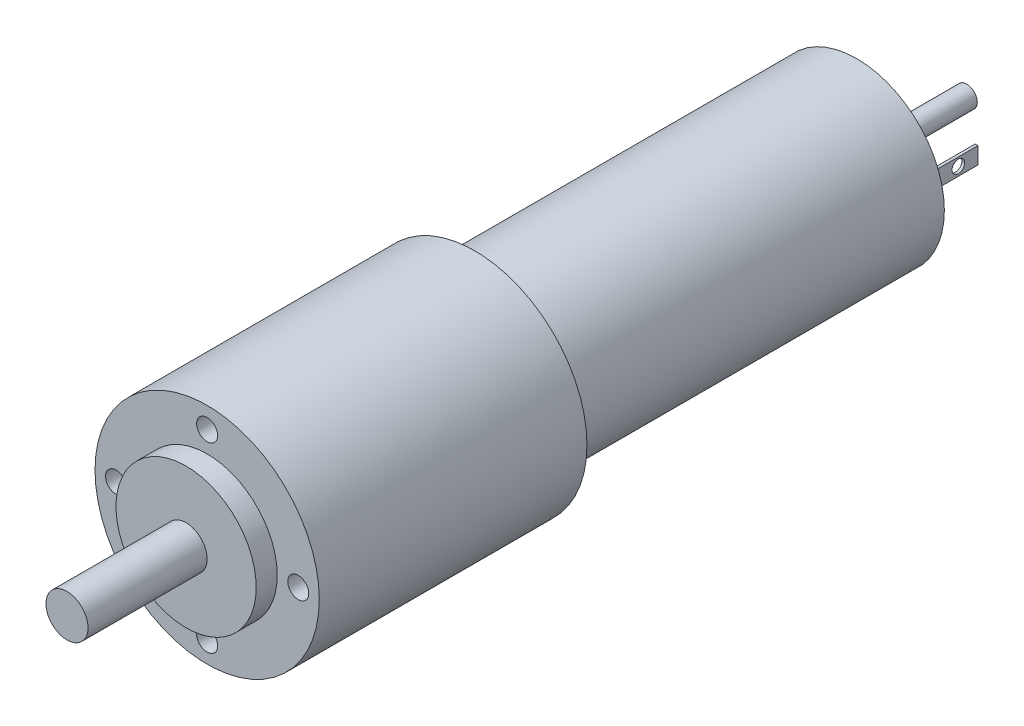
from build123d import *

# Parameters (mm, degrees)
ESQUISSE1_R                  = 16
BOSS_EXTRU_1_DEPTH           = 38.2
ESQUISSE4_R                  = 12.5
BOSS_EXTRU_2_DEPTH           = 54.5
ESQUISSE5_R                  = 10
BOSS_EXTRU_3_DEPTH           = 3
ESQUISSE6_R                  = 3
BOSS_EXTRU_4_DEPTH           = 17
ESQUISSE8_R                  = 4
BOSS_EXTRU_5_DEPTH           = 1.2
ESQUISSE9_R                  = 3
BOSS_EXTRU_6_DEPTH           = 1.5
ESQUISSE10_R                 = 1.5
BOSS_EXTRU_7_DEPTH           = 13
ESQUISSE11_W                 = 0.4
ESQUISSE11_H                 = 2.4
BOSS_EXTRU_8_DEPTH           = 8.3
ESQUISSE14_R                 = 0.9
ENL_V_MAT_EXTRU_2_DEPTH      = 1
R_P_TITION_CIRCULAIRE3_COUNT = 2
R_P_TITION_CIRCULAIRE4_COUNT = 2
ESQUISSE15_R                 = 0.8
ENL_V_MAT_EXTRU_3_DEPTH      = 3
R_P_TITION_CIRCULAIRE5_COUNT = 2
ESQUISSE16_R                 = 1.5
ENL_V_MAT_EXTRU_4_DEPTH      = 4
R_P_TITION_CIRCULAIRE6_COUNT = 4


with BuildPart() as part:
    # Esquisse1 → Boss.-Extru.1 (new body)
    with BuildSketch(Plane.XY):
        Circle(ESQUISSE1_R)
    extrude(amount=BOSS_EXTRU_1_DEPTH)

    # Esquisse4 → Boss.-Extru.2 (add)
    with BuildSketch(Plane(origin=(0, 0, 0), x_dir=(-1, 0, 0), z_dir=(0, 0, -1))):
        with Locations(Location((0, 0, 0), (0, 0, 180))):
            Circle(ESQUISSE4_R)
    extrude(amount=BOSS_EXTRU_2_DEPTH)

    # Esquisse5 → Boss.-Extru.3 (add)
    with BuildSketch(Plane.XY.offset(38.2)):
        Circle(ESQUISSE5_R)
    extrude(amount=BOSS_EXTRU_3_DEPTH)

    # Esquisse6 → Boss.-Extru.4 (add)
    with BuildSketch(Plane.XY.offset(41.2)):
        Circle(ESQUISSE6_R)
    extrude(amount=BOSS_EXTRU_4_DEPTH)

    # Esquisse8 → Boss.-Extru.5 (add)
    with BuildSketch(Plane(origin=(0, 0, -54.5), x_dir=(-1, 0, 0), z_dir=(0, 0, -1))):
        Circle(ESQUISSE8_R)
    extrude(amount=BOSS_EXTRU_5_DEPTH)

    # Esquisse9 → Boss.-Extru.6 (add)
    with BuildSketch(Plane(origin=(0, 0, -55.7), x_dir=(-1, 0, 0), z_dir=(0, 0, -1))):
        with Locations(Location((0, 0, 0), (0, 0, 180))):
            Circle(ESQUISSE9_R)
    extrude(amount=BOSS_EXTRU_6_DEPTH)

    # Esquisse10 → Boss.-Extru.7 (add)
    with BuildSketch(Plane(origin=(0, 0, -57.2), x_dir=(-1, 0, 0), z_dir=(0, 0, -1))):
        with Locations(Location((0, 0, 0), (0, 0, 180))):
            Circle(ESQUISSE10_R)
    extrude(amount=BOSS_EXTRU_7_DEPTH)

    # Esquisse11 → Boss.-Extru.8 (add)
    with BuildSketch(Plane(origin=(0, 0, -54.5), x_dir=(-1, 0, 0), z_dir=(0, 0, -1))):
        with Locations((-8.8, 0.9)):
            Rectangle(ESQUISSE11_W, ESQUISSE11_H)
    boss_extru_8 = extrude(amount=BOSS_EXTRU_8_DEPTH)

    # Esquisse14 → Enlèv. mat.-Extru.2 (cut)
    with BuildSketch(Plane(origin=(9, 0, 0), x_dir=(0, 0, -1), z_dir=(1, 0, 0))):
        with Locations((59.997923429, 0.92616233)):
            Circle(ESQUISSE14_R)
    enl_v_mat_extru_2 = extrude(amount=-ENL_V_MAT_EXTRU_2_DEPTH, mode=Mode.SUBTRACT)

    # Répétition circulaire3: Boss.-Extru.8 ×2 about axis
    r_p_tition_circulaire3_axis = Axis((0, 0, 0), (0, 0, 1))
    for i in range(1, R_P_TITION_CIRCULAIRE3_COUNT):
        add(boss_extru_8.rotate(r_p_tition_circulaire3_axis, i * 360 / R_P_TITION_CIRCULAIRE3_COUNT))

    # Répétition circulaire4: Enlèv. mat.-Extru.2 ×2 about axis
    r_p_tition_circulaire4_axis = Axis((0, 0, -70.2), (0, 0, 1))
    for i in range(1, R_P_TITION_CIRCULAIRE4_COUNT):
        add(enl_v_mat_extru_2.rotate(r_p_tition_circulaire4_axis, i * 360 / R_P_TITION_CIRCULAIRE4_COUNT), mode=Mode.SUBTRACT)

    # Esquisse15 → Enlèv. mat.-Extru.3 (cut)
    with BuildSketch(Plane(origin=(0, 0, -54.5), x_dir=(-1, 0, 0), z_dir=(0, 0, -1))):
        with Locations((-4.210841648, 7.596559423)):
            Circle(ESQUISSE15_R)
    enl_v_mat_extru_3 = extrude(amount=-ENL_V_MAT_EXTRU_3_DEPTH, mode=Mode.SUBTRACT)

    # Répétition circulaire5: Enlèv. mat.-Extru.3 ×2 about axis
    r_p_tition_circulaire5_axis = Axis((0, 0, 0), (0, 0, 1))
    for i in range(1, R_P_TITION_CIRCULAIRE5_COUNT):
        add(enl_v_mat_extru_3.rotate(r_p_tition_circulaire5_axis, i * 360 / R_P_TITION_CIRCULAIRE5_COUNT), mode=Mode.SUBTRACT)

    # Esquisse16 → Enlèv. mat.-Extru.4 (cut)
    with BuildSketch(Plane.XY.offset(38.2)):
        with Locations((-13, 0)):
            Circle(ESQUISSE16_R)
    enl_v_mat_extru_4 = extrude(amount=-ENL_V_MAT_EXTRU_4_DEPTH, mode=Mode.SUBTRACT)

    # Répétition circulaire6: Enlèv. mat.-Extru.4 ×4 about axis
    r_p_tition_circulaire6_axis = Axis((0, 0, 0), (0, 0, 1))
    for i in range(1, R_P_TITION_CIRCULAIRE6_COUNT):
        add(enl_v_mat_extru_4.rotate(r_p_tition_circulaire6_axis, i * 360 / R_P_TITION_CIRCULAIRE6_COUNT), mode=Mode.SUBTRACT)


solid = part.part
